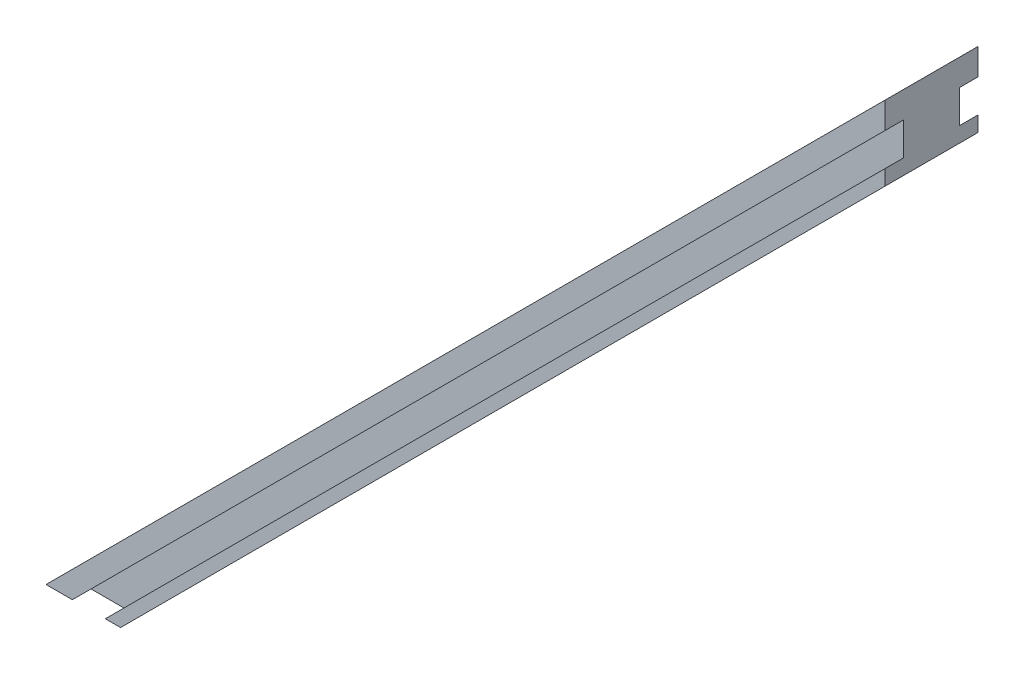
from build123d import *

# Parameters (mm, degrees)
MAIN_DEPTH         = 5
WINDOWSLOT1_DEPTH  = 2
SKETCH6_R          = 1.25
CUT_EXTRUDE2_DEPTH = 5
LPATTERN1_COUNT    = 11
LPATTERN1_PITCH    = 10
SKETCH7_R          = 3.5
CUT_EXTRUDE4_DEPTH = 1.5


with BuildPart() as part:
    # Sketch1 → Main (new body, symmetric)
    with BuildSketch(Plane.XY):
        Polygon((-45, -45), (45, 45), (45, 37), (-37, -45), align=None)
    extrude(amount=MAIN_DEPTH, both=True)

    # Sketch4 → WindowSlot1 (cut)
    with BuildSketch(Plane.XY.offset(5)):
        Polygon((45, 42.171572875), (-42.171572875, -45), (-38.636038969, -45), (45, 38.636038969), align=None)
    windowslot1 = extrude(amount=-WINDOWSLOT1_DEPTH, mode=Mode.SUBTRACT)

    # Mirror1: WindowSlot1 across plane
    add(windowslot1.mirror(Plane.XY), mode=Mode.SUBTRACT)

    # Sketch6 → Cut-Extrude2 (cut)
    with BuildSketch(Plane(origin=(4, -4, 0), x_dir=(0, 0, 1), z_dir=(-0.707106781, 0.707106781, 0))):
        with Locations((0, 50)):
            Circle(SKETCH6_R)
    cut_extrude2 = extrude(amount=CUT_EXTRUDE2_DEPTH, mode=Mode.SUBTRACT)

    # LPattern1: Cut-Extrude2 ×11
    with Locations(*[Vector(-0.707106781, -0.707106781, 0) * (i * LPATTERN1_PITCH) for i in range(1, LPATTERN1_COUNT)]):
        add(cut_extrude2, mode=Mode.SUBTRACT)

    # Sketch7 → Cut-Extrude4 (cut)
    with BuildSketch(Plane(origin=(0, 0, 0), x_dir=(0, 0, 1), z_dir=(-0.707106781, 0.707106781, 0))):
        with Locations((0, 40)):
            Circle(SKETCH7_R)
        with Locations((0, -40)):
            Circle(SKETCH7_R)
    extrude(amount=-CUT_EXTRUDE4_DEPTH, mode=Mode.SUBTRACT)


solid = part.part
